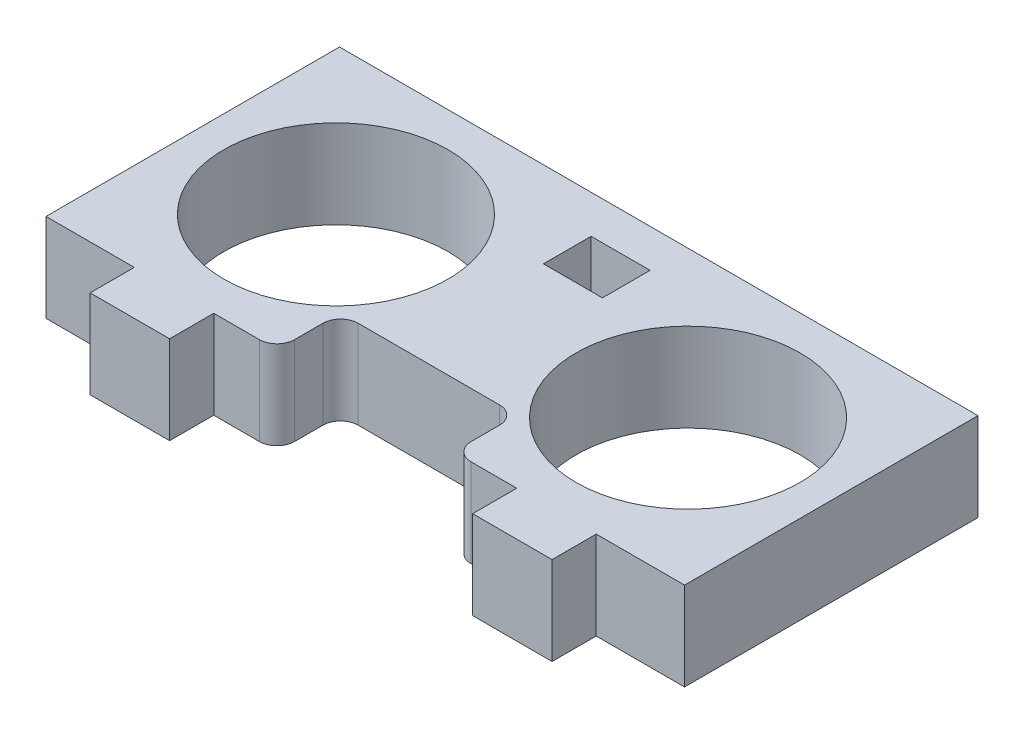
from build123d import *

# Parameters (mm, degrees)
SKETCH1_W           = 45.9232
SKETCH1_H           = 21.1074
SKETCH1_R           = 8.0645
BOSS_EXTRUDE1_DEPTH = 6.35
SKETCH2_W           = 4.2418
SKETCH2_H           = 3.429
SKETCH2_W_2         = 12.7
SKETCH2_H_2         = 4.572
CUT_EXTRUDE1_DEPTH  = 6.35
SKETCH4_W           = 5.715
SKETCH4_H           = 3.175
BOSS_EXTRUDE3_DEPTH = 6.35
FILLET1_R           = 1.27


with BuildPart() as part:
    # Sketch1 → Boss-Extrude1 (new body)
    with BuildSketch(Plane(origin=(0, 0, 0), x_dir=(1, 0, 0), z_dir=(0, 1, 0))):
        Rectangle(SKETCH1_W, SKETCH1_H)
        with Locations((-12.6619, 0)):
            Circle(SKETCH1_R, mode=Mode.SUBTRACT)
        with Locations((12.6619, 0)):
            Circle(SKETCH1_R, mode=Mode.SUBTRACT)
    extrude(amount=BOSS_EXTRUDE1_DEPTH)

    # Sketch2 → Cut-Extrude1 (cut)
    with BuildSketch(Plane(origin=(0, 6.35, 0), x_dir=(1, 0, 0), z_dir=(0, 1, 0))):
        with Locations((0, 6.096)):
            Rectangle(SKETCH2_W, SKETCH2_H)
        with Locations((0, -8.2677)):
            Rectangle(SKETCH2_W_2, SKETCH2_H_2)
    extrude(amount=-CUT_EXTRUDE1_DEPTH, mode=Mode.SUBTRACT)

    # Sketch4 → Boss-Extrude3 (add)
    with BuildSketch(Plane(origin=(0, 6.35, 0), x_dir=(1, 0, 0), z_dir=(0, 1, 0))):
        with Locations((-13.7541, -12.1412)):
            Rectangle(SKETCH4_W, SKETCH4_H)
        with Locations((13.7541, -12.1412)):
            Rectangle(SKETCH4_W, SKETCH4_H)
    extrude(amount=-BOSS_EXTRUDE3_DEPTH)

    # Fillet1
    fillet1_edges = [part.edges().sort_by_distance(p)[0] for p in [
        (-6.35, 3.175, 10.5537),
        (-6.35, 3.175, 5.9817),
        (6.35, 3.175, 5.9817),
        (6.35, 3.175, 10.5537),
    ]]
    fillet(fillet1_edges, radius=FILLET1_R)


solid = part.part
